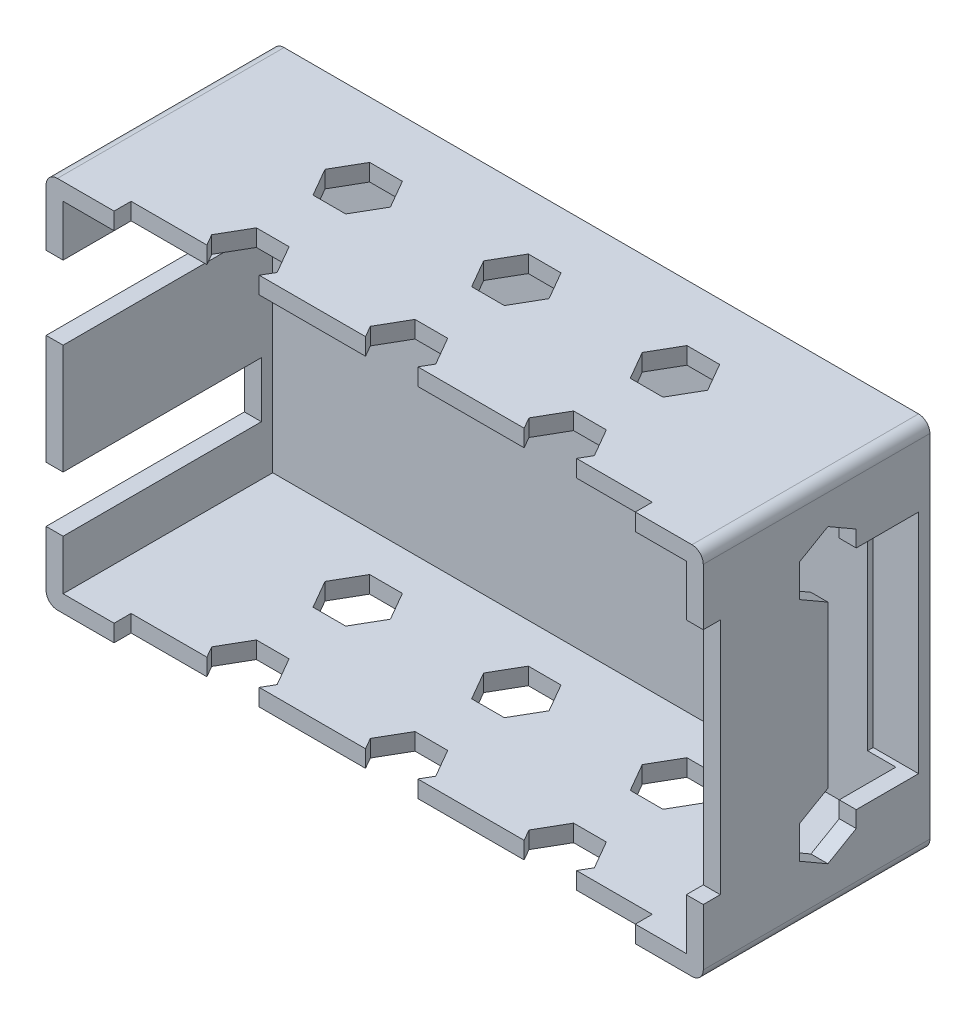
from build123d import *

# Parameters (mm, degrees)
SKETCH_1_W           = 116
SKETCH_1_H           = 70
EXTRUDE_1_DEPTH      = 66
SKETCH_2_W           = 110
SKETCH_2_H           = 60
CUT_EXTRUDE_1_DEPTH  = 67
CUT_EXTRUDE_2_REACH  = 118
SKETCH_3_W           = 65
SKETCH_3_H           = 13
CUT_EXTRUDE_3_REACH  = 118
SKETCH_4_W           = 65
SKETCH_4_H           = 9.8
CUT_EXTRUDE_4_REACH  = 68
SKETCH_5_W           = 92
SKETCH_5_H           = 3
CUT_EXTRUDE_5_REACH  = 118
SKETCH_6_W           = 33
SKETCH_6_H           = 42
SKETCH_7_W           = 92
SKETCH_7_H           = 3
CUT_EXTRUDE_6_DEPTH  = 67
CUT_EXTRUDE_7_DEPTH  = 4
CUT_EXTRUDE_8_DEPTH  = 4
CUT_EXTRUDE_9_DEPTH  = 4
CUT_EXTRUDE_10_DEPTH = 4
CUT_EXTRUDE_11_DEPTH = 4
CUT_EXTRUDE_12_REACH = 118
CUT_EXTRUDE_13_DEPTH = 67
CUT_EXTRUDE_14_DEPTH = 67
CUT_EXTRUDE_15_DEPTH = 67
CUT_EXTRUDE_16_DEPTH = 67
CUT_EXTRUDE_17_DEPTH = 67
CUT_EXTRUDE_18_REACH = 68
CUT_EXTRUDE_19_REACH = 118
CUT_EXTRUDE_20_DEPTH = 67
FILLET_1_R           = 2
SKETCH_22_W          = 129.509915456
SKETCH_22_H          = 79.224014217
CUT_EXTRUDE_22_DEPTH = 30
SKETCH_23_W          = 92
SKETCH_23_H          = 66
CUT_EXTRUDE_23_DEPTH = 3
CUT_EXTRUDE_24_DEPTH = 8


with BuildPart() as part:
    # 스케치1 → 보스-돌출1 (new body)
    with BuildSketch(Plane.XZ.offset(33)):
        with Locations((0, 35)):
            Rectangle(SKETCH_1_W, SKETCH_1_H)
    extrude(amount=-EXTRUDE_1_DEPTH)

    # 스케치2 → 컷-돌출1 (cut)
    with BuildSketch(Plane.XY.offset(70)):
        Rectangle(SKETCH_2_W, SKETCH_2_H)
    extrude(amount=-CUT_EXTRUDE_1_DEPTH, mode=Mode.SUBTRACT)

    # 스케치3 → 컷-돌출2 (cut, up to next)
    with BuildSketch(Plane.ZY.offset(58), mode=Mode.PRIVATE) as cut_extrude_2_sk1:
        with Locations((37.5, 14.5)):
            Rectangle(SKETCH_3_W, SKETCH_3_H)
    cut_extrude_2_tool1 = extrude(cut_extrude_2_sk1.sketch, amount=-CUT_EXTRUDE_2_REACH, mode=Mode.PRIVATE) & part.part
    add(cut_extrude_2_tool1.solids().sort_by_distance((-58, 14.5, 37.5))[0], mode=Mode.SUBTRACT)

    # 스케치4 → 컷-돌출3 (cut, up to next)
    with BuildSketch(Plane.ZY.offset(58), mode=Mode.PRIVATE) as cut_extrude_3_sk1:
        with Locations((37.5, -16.3)):
            Rectangle(SKETCH_4_W, SKETCH_4_H)
    cut_extrude_3_tool1 = extrude(cut_extrude_3_sk1.sketch, amount=-CUT_EXTRUDE_3_REACH, mode=Mode.PRIVATE) & part.part
    add(cut_extrude_3_tool1.solids().sort_by_distance((-58, -16.3, 37.5))[0], mode=Mode.SUBTRACT)

    # 스케치5 → 컷-돌출4 (cut, up to next)
    with BuildSketch(Plane.XZ.offset(33), mode=Mode.PRIVATE) as cut_extrude_4_sk1:
        with Locations((0, 68.5)):
            Rectangle(SKETCH_5_W, SKETCH_5_H)
    cut_extrude_4_tool1 = extrude(cut_extrude_4_sk1.sketch, amount=-CUT_EXTRUDE_4_REACH, mode=Mode.PRIVATE) & part.part
    add(cut_extrude_4_tool1.solids().sort_by_distance((0, -33, 68.5))[0], mode=Mode.SUBTRACT)

    # 스케치6 → 컷-돌출5 (cut, up to next)
    with BuildSketch(Plane(origin=(58, 0, 0), x_dir=(0, 0, -1), z_dir=(1, 0, 0)), mode=Mode.PRIVATE) as cut_extrude_5_sk1:
        with Locations((-53.5, 0)):
            Rectangle(SKETCH_6_W, SKETCH_6_H)
    cut_extrude_5_tool1 = extrude(cut_extrude_5_sk1.sketch, amount=-CUT_EXTRUDE_5_REACH, mode=Mode.PRIVATE) & part.part
    add(cut_extrude_5_tool1.solids().sort_by_distance((58, 0, 53.5))[0], mode=Mode.SUBTRACT)

    # 스케치7 → 컷-돌출6 (cut, through all)
    with BuildSketch(Plane(origin=(0, 33, 0), x_dir=(-1, 0, 0), z_dir=(0, 1, 0))):
        with Locations((0, 68.5)):
            Rectangle(SKETCH_7_W, SKETCH_7_H)
    extrude(amount=-CUT_EXTRUDE_6_DEPTH, mode=Mode.SUBTRACT)

    # 스케치8 → 컷-돌출7 (cut, through all)
    with BuildSketch(Plane.XZ.offset(-30)):
        Polygon((-33.773502692, 35), (-30.886751346, 30), (-25.113248654, 30), (-22.226497308, 35), (-25.113248654, 40), (-30.886751346, 40), align=None)
    extrude(amount=-CUT_EXTRUDE_7_DEPTH, mode=Mode.SUBTRACT)

    # 스케치9 → 컷-돌출8 (cut, through all)
    with BuildSketch(Plane.XZ.offset(-30)):
        Polygon((-5.773502692, 35), (-2.886751346, 30), (2.886751346, 30), (5.773502692, 35), (2.886751346, 40), (-2.886751346, 40), align=None)
    extrude(amount=-CUT_EXTRUDE_8_DEPTH, mode=Mode.SUBTRACT)

    # 스케치10 → 컷-돌출9 (cut, through all)
    with BuildSketch(Plane.XZ.offset(-30)):
        Polygon((22.226497308, 35), (25.113248654, 30), (30.886751346, 30), (33.773502692, 35), (30.886751346, 40), (25.113248654, 40), align=None)
    extrude(amount=-CUT_EXTRUDE_9_DEPTH, mode=Mode.SUBTRACT)

    # 스케치11 → 컷-돌출10 (cut, through all)
    with BuildSketch(Plane.XZ.offset(-30)):
        Polygon((22.226497308, 15), (25.113248654, 10), (30.886751346, 10), (33.773502692, 15), (30.886751346, 20), (25.113248654, 20), align=None)
    extrude(amount=-CUT_EXTRUDE_10_DEPTH, mode=Mode.SUBTRACT)

    # 스케치12 → 컷-돌출11 (cut, through all)
    with BuildSketch(Plane.XZ.offset(-30)):
        Polygon((-5.773502692, 15), (-2.886751346, 10), (2.886751346, 10), (5.773502692, 15), (2.886751346, 20), (-2.886751346, 20), align=None)
    extrude(amount=-CUT_EXTRUDE_11_DEPTH, mode=Mode.SUBTRACT)

    # 스케치13 → 컷-돌출12 (cut, up to next)
    with BuildSketch(Plane(origin=(58, 0, 0), x_dir=(0, 0, -1), z_dir=(1, 0, 0)), mode=Mode.PRIVATE) as cut_extrude_12_sk1:
        Polygon((-23, -17.113248654), (-23, -22.886751346), (-18, -25.773502692), (-13, -22.886751346), (-13, -17.113248654), (-18, -14.226497308), align=None)
    cut_extrude_12_tool1 = extrude(cut_extrude_12_sk1.sketch, amount=-CUT_EXTRUDE_12_REACH, mode=Mode.PRIVATE) & part.part
    add(cut_extrude_12_tool1.solids().sort_by_distance((58, -20, 18))[0], mode=Mode.SUBTRACT)

    # 스케치14 → 컷-돌출13 (cut, through all)
    with BuildSketch(Plane.XZ.offset(33)):
        Polygon((-25.113248654, 40), (-30.886751346, 40), (-33.773502692, 35), (-30.886751346, 30), (-25.113248654, 30), (-22.226497308, 35), align=None)
    extrude(amount=-CUT_EXTRUDE_13_DEPTH, mode=Mode.SUBTRACT)

    # 스케치15 → 컷-돌출14 (cut, through all)
    with BuildSketch(Plane.XZ.offset(33)):
        Polygon((2.886751346, 40), (-2.886751346, 40), (-5.773502692, 35), (-2.886751346, 30), (2.886751346, 30), (5.773502692, 35), align=None)
    extrude(amount=-CUT_EXTRUDE_14_DEPTH, mode=Mode.SUBTRACT)

    # 스케치16 → 컷-돌출15 (cut, through all)
    with BuildSketch(Plane.XZ.offset(33)):
        Polygon((30.886751346, 40), (25.113248654, 40), (22.226497308, 35), (25.113248654, 30), (30.886751346, 30), (33.773502692, 35), align=None)
    extrude(amount=-CUT_EXTRUDE_15_DEPTH, mode=Mode.SUBTRACT)

    # 스케치17 → 컷-돌출16 (cut, through all)
    with BuildSketch(Plane.XZ.offset(33)):
        Polygon((30.886751346, 20), (25.113248654, 20), (22.226497308, 15), (25.113248654, 10), (30.886751346, 10), (33.773502692, 15), align=None)
    extrude(amount=-CUT_EXTRUDE_16_DEPTH, mode=Mode.SUBTRACT)

    # 스케치18 → 컷-돌출17 (cut, through all)
    with BuildSketch(Plane.XZ.offset(33)):
        Polygon((2.886751346, 20), (-2.886751346, 20), (-5.773502692, 15), (-2.886751346, 10), (2.886751346, 10), (5.773502692, 15), align=None)
    extrude(amount=-CUT_EXTRUDE_17_DEPTH, mode=Mode.SUBTRACT)

    # 스케치19 → 컷-돌출18 (cut, up to next)
    with BuildSketch(Plane.XZ.offset(33), mode=Mode.PRIVATE) as cut_extrude_18_sk1:
        Polygon((-25.113248654, 20), (-30.886751346, 20), (-33.773502692, 15), (-30.886751346, 10), (-25.113248654, 10), (-22.226497308, 15), align=None)
    cut_extrude_18_tool1 = extrude(cut_extrude_18_sk1.sketch, amount=-CUT_EXTRUDE_18_REACH, mode=Mode.PRIVATE) & part.part
    add(cut_extrude_18_tool1.solids().sort_by_distance((-28, -33, 15))[0], mode=Mode.SUBTRACT)

    # 스케치20 → 컷-돌출19 (cut, up to next)
    with BuildSketch(Plane(origin=(58, 0, 0), x_dir=(0, 0, -1), z_dir=(1, 0, 0)), mode=Mode.PRIVATE) as cut_extrude_19_sk1:
        Polygon((-18, 25.773502692), (-23, 22.886751346), (-23, 17.113248654), (-18, 14.226497308), (-13, 17.113248654), (-13, 22.886751346), align=None)
    cut_extrude_19_tool1 = extrude(cut_extrude_19_sk1.sketch, amount=-CUT_EXTRUDE_19_REACH, mode=Mode.PRIVATE) & part.part
    add(cut_extrude_19_tool1.solids().sort_by_distance((58, 20, 18))[0], mode=Mode.SUBTRACT)

    # 스케치21 → 컷-돌출20 (cut, through all)
    with BuildSketch(Plane(origin=(0, 33, 0), x_dir=(-1, 0, 0), z_dir=(0, 1, 0))):
        Polygon((22.226497308, 15), (25.113248654, 10), (30.886751346, 10), (33.773502692, 15), (30.886751346, 20), (25.113248654, 20), align=None)
    extrude(amount=-CUT_EXTRUDE_20_DEPTH, mode=Mode.SUBTRACT)

    # 필렛1
    fillet_1_edges = [part.edges().sort_by_distance(p)[0] for p in [
        (58, 33, 35),
        (-58, 33, 35),
        (58, -33, 35),
        (-58, -33, 35),
    ]]
    fillet(fillet_1_edges, radius=FILLET_1_R)

    # 스케치22 → 컷-돌출22 (cut)
    with BuildSketch(Plane.XY.offset(70)):
        with Locations((1.80270212, -0.616713883)):
            Rectangle(SKETCH_22_W, SKETCH_22_H)
    extrude(amount=-CUT_EXTRUDE_22_DEPTH, mode=Mode.SUBTRACT)

    # 스케치23 → 컷-돌출23 (cut)
    with BuildSketch(Plane.XY.offset(40)):
        Rectangle(SKETCH_23_W, SKETCH_23_H)
    extrude(amount=-CUT_EXTRUDE_23_DEPTH, mode=Mode.SUBTRACT)

    # 스케치24 → 컷-돌출24 (cut)
    with BuildSketch(Plane(origin=(58, 0, 0), x_dir=(0, 0, -1), z_dir=(1, 0, 0))):
        Polygon((-18, -14.226497308), (-18, 14.226497308), (-13, 20), (-2, 20), (-2, -20), (-13, -20), align=None)
    extrude(amount=-CUT_EXTRUDE_24_DEPTH, mode=Mode.SUBTRACT)


solid = part.part
